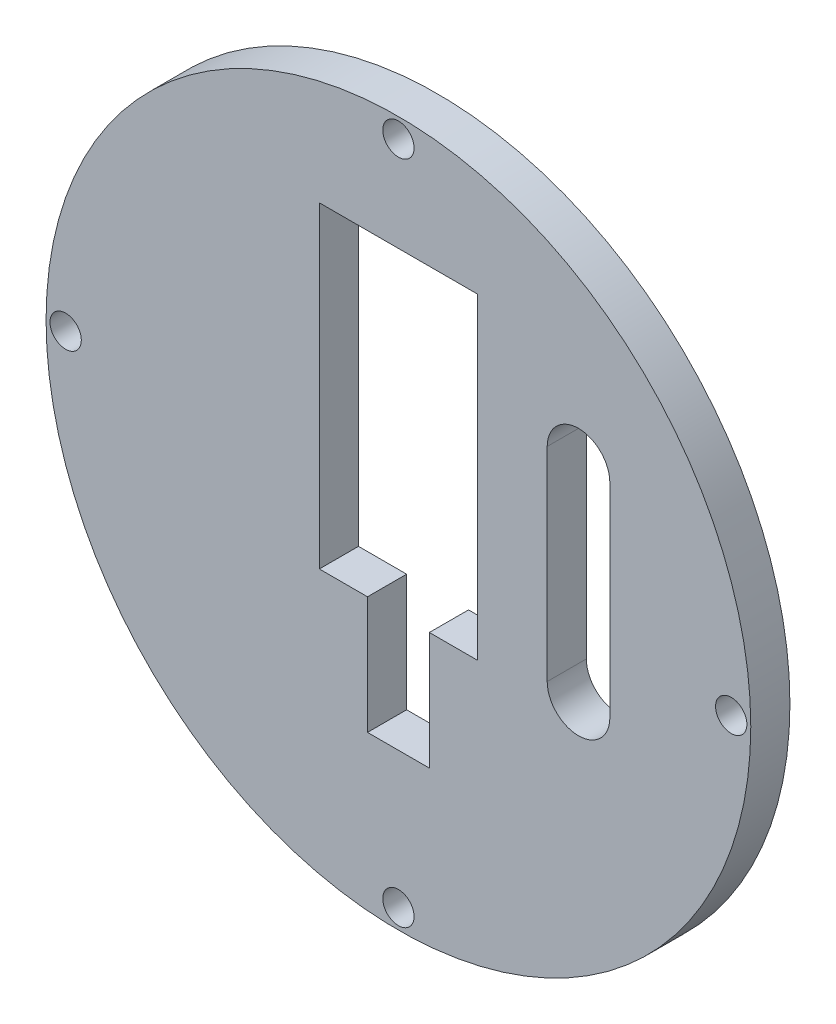
from build123d import *

# Parameters (mm, degrees)
SKETCH1_R           = 45
SKETCH1_R_2         = 2
SKETCH1_W           = 20.2
SKETCH1_H           = 40.5
BOSS_EXTRUDE1_DEPTH = 5
SKETCH2_W           = 7.9
SKETCH2_H           = 15
CUT_EXTRUDE1_DEPTH  = 10
CUT_EXTRUDE2_DEPTH  = 10


with BuildPart() as part:
    # Sketch1 → Boss-Extrude1 (new body)
    with BuildSketch(Plane.XY):
        Circle(SKETCH1_R)
        with Locations((42.5, 0)):
            Circle(SKETCH1_R_2, mode=Mode.SUBTRACT)
        with Locations((0, -42.5)):
            Circle(SKETCH1_R_2, mode=Mode.SUBTRACT)
        with Locations((-42.5, 0)):
            Circle(SKETCH1_R_2, mode=Mode.SUBTRACT)
        with Locations((0, 42.5)):
            Circle(SKETCH1_R_2, mode=Mode.SUBTRACT)
        with Locations((0, 10.15)):
            Rectangle(SKETCH1_W, SKETCH1_H, mode=Mode.SUBTRACT)
    extrude(amount=BOSS_EXTRUDE1_DEPTH)

    # Sketch2 → Cut-Extrude1 (cut)
    with BuildSketch(Plane(origin=(0, 0, 0), x_dir=(-1, 0, 0), z_dir=(0, 0, -1))):
        with Locations((0, -17.6)):
            Rectangle(SKETCH2_W, SKETCH2_H)
    extrude(amount=-CUT_EXTRUDE1_DEPTH, mode=Mode.SUBTRACT)

    # Sketch3 → Cut-Extrude2 (cut)
    with BuildSketch(Plane(origin=(0, 0, 0), x_dir=(-1, 0, 0), z_dir=(0, 0, -1))):
        with BuildLine():
            Line((-19, 18), (-19, -8))
            ThreePointArc((-19, -8), (-23, -12), (-27, -8))
            Line((-27, -8), (-27, 18))
            ThreePointArc((-27, 18), (-23, 22), (-19, 18))
        make_face()
    extrude(amount=-CUT_EXTRUDE2_DEPTH, mode=Mode.SUBTRACT)


solid = part.part
